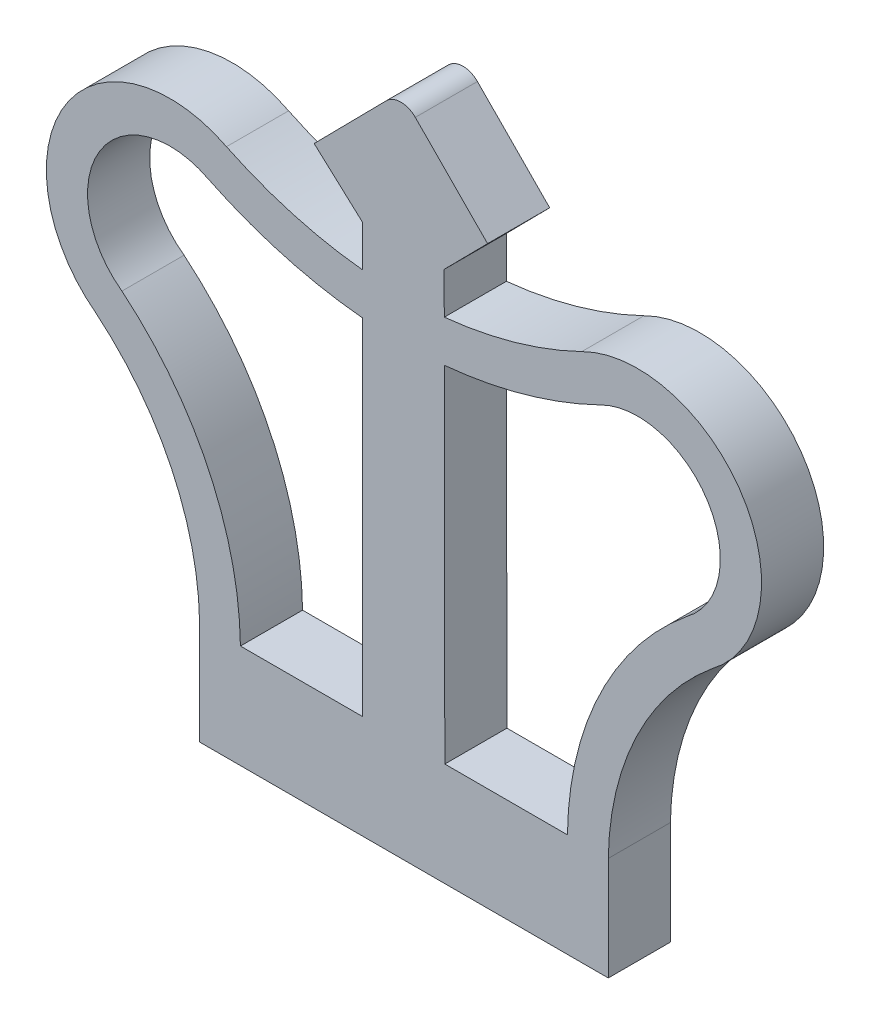
from build123d import *

# Parameters (mm, degrees)
SALIENTE_EXTRUIR1_DEPTH = 3


with BuildPart() as part:
    # Model → Saliente-Extruir1 (new body)
    with BuildSketch(Plane.XY):
        with BuildLine():
            Line((52.126339564, 0.69142602), (71.859672897, 0.69142602))
            Line((71.859672897, 0.69142602), (71.859672897, 5.69142602))
            ThreePointArc((71.859672897, 5.69142602), (73.216437638, 11.459046612), (76.864886687, 16.127566441))
            ThreePointArc((76.864886687, 16.127566441), (78.358673415, 24.066839848), (70.578789676, 26.243275014))
            ThreePointArc((70.578789676, 26.243275014), (67.341569383, 25.013085855), (63.940045397, 24.363012656))
            Line((63.940045397, 24.363012656), (63.937229303, 26.362731754))
            Line((63.937229303, 26.362731754), (66.030265375, 28.484052098))
            Line((66.030265375, 28.484052098), (62.541871922, 32.019586004))
            ThreePointArc((62.541871922, 32.019586004), (61.844193231, 32.30857398), (61.14651454, 32.019586004))
            Line((61.14651454, 32.019586004), (57.658121086, 28.484052098))
            Line((57.658121086, 28.484052098), (59.990562636, 26.362731754))
            Line((59.990562636, 26.362731754), (59.990562636, 24.368482398))
            ThreePointArc((59.990562636, 24.368482398), (56.626825565, 25.017616984), (53.424360475, 26.234301063))
            ThreePointArc((53.424360475, 26.234301063), (45.632437064, 24.074933253), (47.121132781, 16.127561055))
            ThreePointArc((47.121132781, 16.127561055), (48.940005662, 14.312179557), (50.391114233, 12.191285299))
            ThreePointArc((50.391114233, 12.191285299), (51.660499902, 9.048614396), (52.126339564, 5.69142602))
            Line((52.126339564, 5.69142602), (52.126339564, 0.69142602))
        make_face()
        with BuildLine():
            Line((59.990562636, 22.359186797), (59.990562636, 5.69142602))
            Line((59.990562636, 5.69142602), (54.098159046, 5.69142602))
            ThreePointArc((54.098159046, 5.69142602), (52.556239166, 12.312269616), (48.376647716, 17.673622257))
            ThreePointArc((48.376647716, 17.673622257), (47.306956592, 22.997651717), (52.54077152, 24.445653821))
            ThreePointArc((52.54077152, 24.445653821), (56.172655621, 23.070320202), (59.990562636, 22.359186797))
        make_face(mode=Mode.SUBTRACT)
        with BuildLine():
            Line((63.966339564, 5.69142602), (63.942873914, 22.354472252))
            ThreePointArc((63.942873914, 22.354472252), (67.795799116, 23.065868121), (71.459909133, 24.453461173))
            ThreePointArc((71.459909133, 24.453461173), (76.670564355, 23.010720068), (75.647074312, 17.701774987))
            ThreePointArc((75.647074312, 17.701774987), (71.439696493, 12.333149563), (69.886739491, 5.69142602))
            Line((69.886739491, 5.69142602), (63.966339564, 5.69142602))
        make_face(mode=Mode.SUBTRACT)
    extrude(amount=SALIENTE_EXTRUIR1_DEPTH)


solid = part.part
